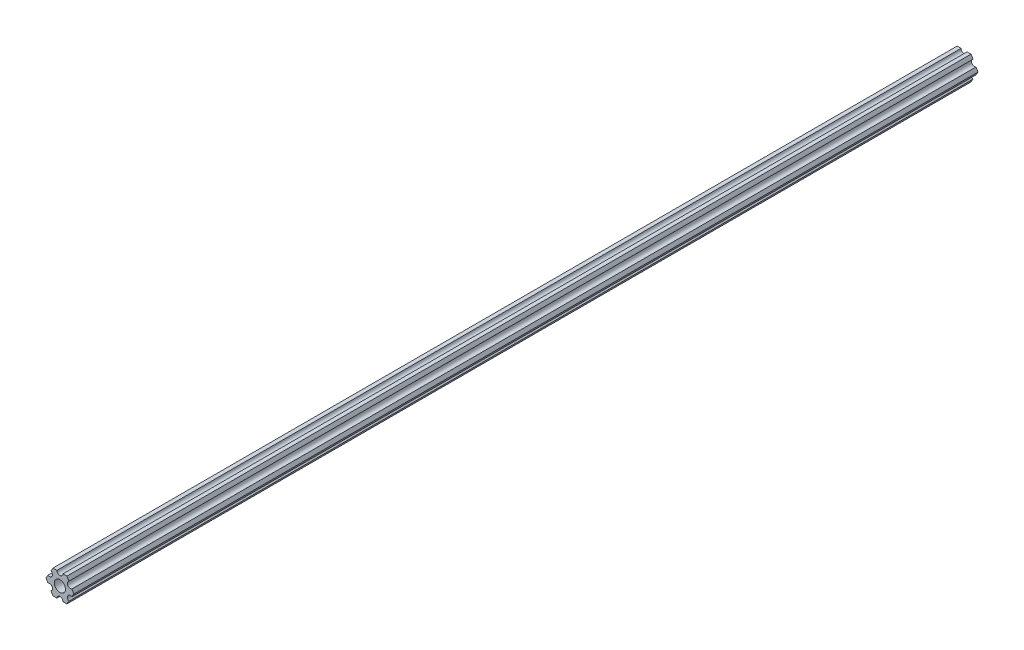
from build123d import *

# Parameters (mm, degrees)
SKETCH1_R           = 2.9337
BOSS_EXTRUDE1_DEPTH = 476.25


with BuildPart() as part:
    # Sketch1 → Boss-Extrude1 (new body)
    with BuildSketch(Plane(origin=(0, 0, 0), x_dir=(-1, 0, 0), z_dir=(0, 0, -1))):
        with BuildLine():
            Line((-4.70551159, -4.549815043), (-3.666174521, -6.349999904))
            Line((-3.666174521, -6.349999904), (-1.587500385, -6.349999904))
            ThreePointArc((-1.587500385, -6.349999904), (-3.85e-07, -4.762499904), (1.587499615, -6.349999904))
            Line((1.587499615, -6.349999904), (3.666173825, -6.349999904))
            Line((3.666173825, -6.349999904), (4.705510942, -4.54981524))
            ThreePointArc((4.705510942, -4.54981524), (4.124445629, -2.381249907), (6.293010962, -1.800184594))
            Line((6.293010962, -1.800184594), (7.332348079, 7e-08))
            Line((7.332348079, 7e-08), (6.293011217, 1.800184685))
            ThreePointArc((6.293011217, 1.800184685), (4.124445939, 2.381250203), (4.705511457, 4.549815481))
            Line((4.705511457, 4.549815481), (3.666174521, 6.350000222))
            Line((3.666174521, 6.350000222), (1.587500385, 6.350000222))
            ThreePointArc((1.587500385, 6.350000222), (3.85e-07, 4.762500222), (-1.587499615, 6.350000222))
            Line((-1.587499615, 6.350000222), (-3.666173825, 6.350000222))
            Line((-3.666173825, 6.350000222), (-4.705511038, 4.549815614))
            ThreePointArc((-4.705511038, 4.549815614), (-4.124445841, 2.38125025), (-6.293011205, 1.800185053))
            Line((-6.293011205, 1.800185053), (-7.332348419, 4.44e-07))
            Line((-7.332348419, 4.44e-07), (-6.293011423, -1.80018429))
            ThreePointArc((-6.293011423, -1.80018429), (-4.12444613, -2.38124975), (-4.70551159, -4.549815043))
        make_face()
        Circle(SKETCH1_R, mode=Mode.SUBTRACT)
    extrude(amount=-BOSS_EXTRUDE1_DEPTH)


solid = part.part
